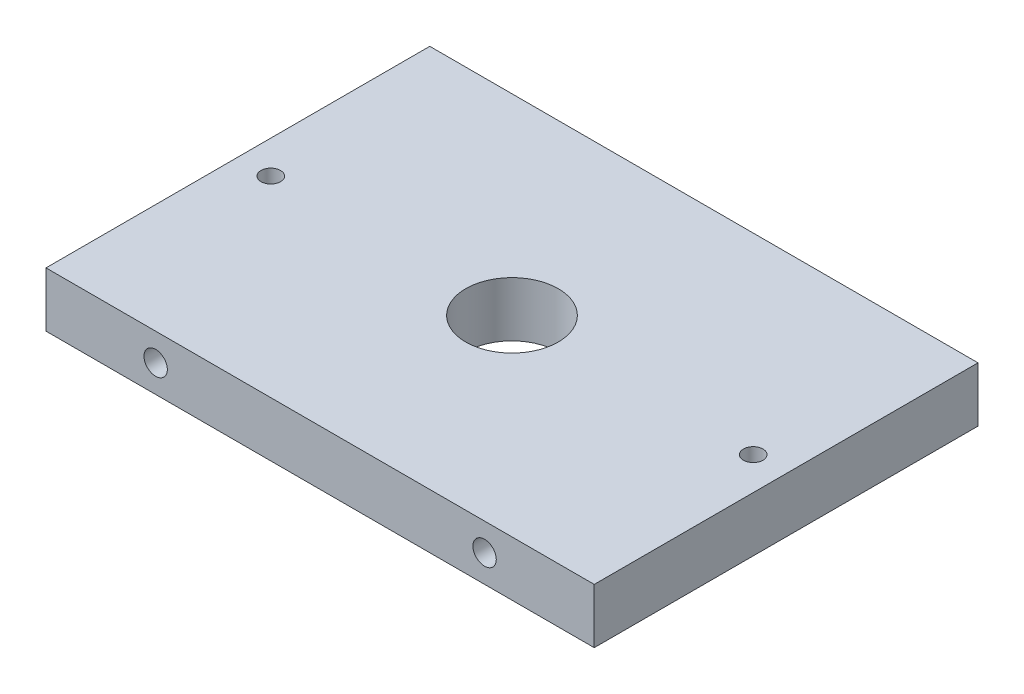
from build123d import *

# Parameters (mm, degrees)
SKETCH1_W                       = 63.5
SKETCH1_H                       = 44.45
BOSS_EXTRUDE1_DEPTH             = 6.35
LPATTERN1_COUNT                 = 2
LPATTERN1_PITCH                 = 55.88
TAP_DRILL_FOR_6_32_TAP1_D       = 2.7051
TAP_DRILL_FOR_6_32_TAP1_DEPTH   = 6.35
TAP_DRILL_FOR_6_32_TAP1_TIP     = 0.81269403
TAP_DRILL_FOR_6_32_TAP2_D       = 2.7051
TAP_DRILL_FOR_6_32_TAP2_DEPTH   = 6.35
TAP_DRILL_FOR_6_32_TAP2_TIP     = 0.81269403
TAP_DRILL_FOR_1_2_13_TAP1_D     = 10.71626
TAP_DRILL_FOR_1_2_13_TAP1_DEPTH = 6.35
TAP_DRILL_FOR_1_2_13_TAP1_TIP   = 3.219489309


with BuildPart() as part:
    # Sketch1 → Boss-Extrude1 (new body)
    with BuildSketch(Plane(origin=(0, 0, 0), x_dir=(1, 0, 0), z_dir=(0, 1, 0))):
        with Locations((4.75259427, -18.964156798)):
            Rectangle(SKETCH1_W, SKETCH1_H)
    extrude(amount=BOSS_EXTRUDE1_DEPTH)

    # Sketch16 → Tap Drill for #4-40 Tap1 (revolve, cut)
    with BuildSketch(Plane(origin=(-23.18740573, 0, 18.964156798), x_dir=(0, 0, -1), z_dir=(1, 0, 0))):
        Polygon((0, 0), (0, 13.379152758), (1.1303, 12.7), (1.1303, 0), align=None)
    tap_drill_for_4_40_tap1 = revolve(axis=Axis((-23.18740573, -6.35, 18.964156798), (0, 1, 0)), mode=Mode.SUBTRACT)

    # LPattern1: Tap Drill for #4-40 Tap1 ×2
    with Locations(*[(i * LPATTERN1_PITCH, 0, 0) for i in range(1, LPATTERN1_COUNT)]):
        add(tap_drill_for_4_40_tap1, mode=Mode.SUBTRACT)

    # Tap Drill for #6-32 Tap1
    with Locations(Plane.XY.offset(41.189156798)):
        with Locations((23.80259427, 3.175), (-14.29740573, 3.175)):
            Hole(TAP_DRILL_FOR_6_32_TAP1_D / 2, depth=TAP_DRILL_FOR_6_32_TAP1_DEPTH)
            with Locations((0, 0, -(TAP_DRILL_FOR_6_32_TAP1_DEPTH + TAP_DRILL_FOR_6_32_TAP1_TIP / 2))):  # 118° drill point
                Cone(0, TAP_DRILL_FOR_6_32_TAP1_D / 2, TAP_DRILL_FOR_6_32_TAP1_TIP, mode=Mode.SUBTRACT)

    # Tap Drill for #6-32 Tap2
    with Locations(Plane(origin=(0, 0, -3.260843202), x_dir=(-1, 0, 0), z_dir=(0, 0, -1))):
        with Locations((14.29740573, 3.175), (-23.80259427, 3.175)):
            Hole(TAP_DRILL_FOR_6_32_TAP2_D / 2, depth=TAP_DRILL_FOR_6_32_TAP2_DEPTH)
            with Locations((0, 0, -(TAP_DRILL_FOR_6_32_TAP2_DEPTH + TAP_DRILL_FOR_6_32_TAP2_TIP / 2))):  # 118° drill point
                Cone(0, TAP_DRILL_FOR_6_32_TAP2_D / 2, TAP_DRILL_FOR_6_32_TAP2_TIP, mode=Mode.SUBTRACT)

    # Tap Drill for 1/2-13 Tap1
    with Locations(Plane(origin=(0, 6.35, 0), x_dir=(-1, 0, 0), z_dir=(0, 1, 0))):
        with Locations((-4.75259427, 18.964156798)):
            Hole(TAP_DRILL_FOR_1_2_13_TAP1_D / 2, depth=TAP_DRILL_FOR_1_2_13_TAP1_DEPTH)
            with Locations((0, 0, -(TAP_DRILL_FOR_1_2_13_TAP1_DEPTH + TAP_DRILL_FOR_1_2_13_TAP1_TIP / 2))):  # 118° drill point
                Cone(0, TAP_DRILL_FOR_1_2_13_TAP1_D / 2, TAP_DRILL_FOR_1_2_13_TAP1_TIP, mode=Mode.SUBTRACT)


solid = part.part
